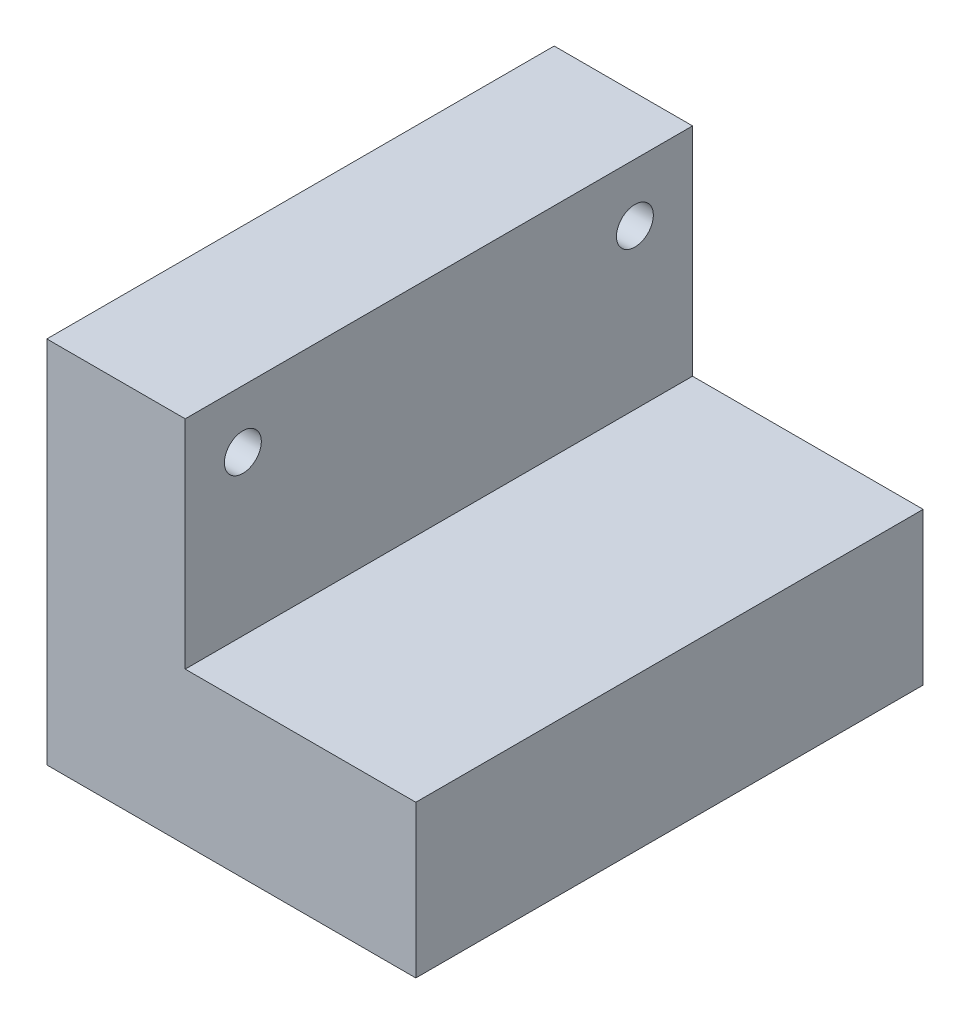
from build123d import *

# Parameters (mm, degrees)
SKETCH1_W           = 80
SKETCH1_H           = 110
BOSS_EXTRUDE1_DEPTH = 80
SKETCH2_W           = 50
SKETCH2_H           = 110
CUT_EXTRUDE2_DEPTH  = 47
SKETCH3_R           = 4
CUT_EXTRUDE3_DEPTH  = 81


with BuildPart() as part:
    # Sketch1 → Boss-Extrude1 (new body)
    with BuildSketch(Plane(origin=(0, 0, 0), x_dir=(1, 0, 0), z_dir=(0, 1, 0))):
        with Locations((10.955882353, 0.606617647)):
            Rectangle(SKETCH1_W, SKETCH1_H)
    extrude(amount=BOSS_EXTRUDE1_DEPTH)

    # Sketch2 → Cut-Extrude2 (cut)
    with BuildSketch(Plane(origin=(0, 80, 0), x_dir=(1, 0, 0), z_dir=(0, 1, 0))):
        with Locations((25.955882353, 0.606617647)):
            Rectangle(SKETCH2_W, SKETCH2_H)
    extrude(amount=-CUT_EXTRUDE2_DEPTH, mode=Mode.SUBTRACT)

    # Sketch3 → Cut-Extrude3 (cut, through all)
    with BuildSketch(Plane.ZY.offset(29.044117647)):
        with Locations((41.893382353, 67.5)):
            Circle(SKETCH3_R)
        with Locations((-43.106617647, 67.5)):
            Circle(SKETCH3_R)
    extrude(amount=-CUT_EXTRUDE3_DEPTH, mode=Mode.SUBTRACT)


solid = part.part
